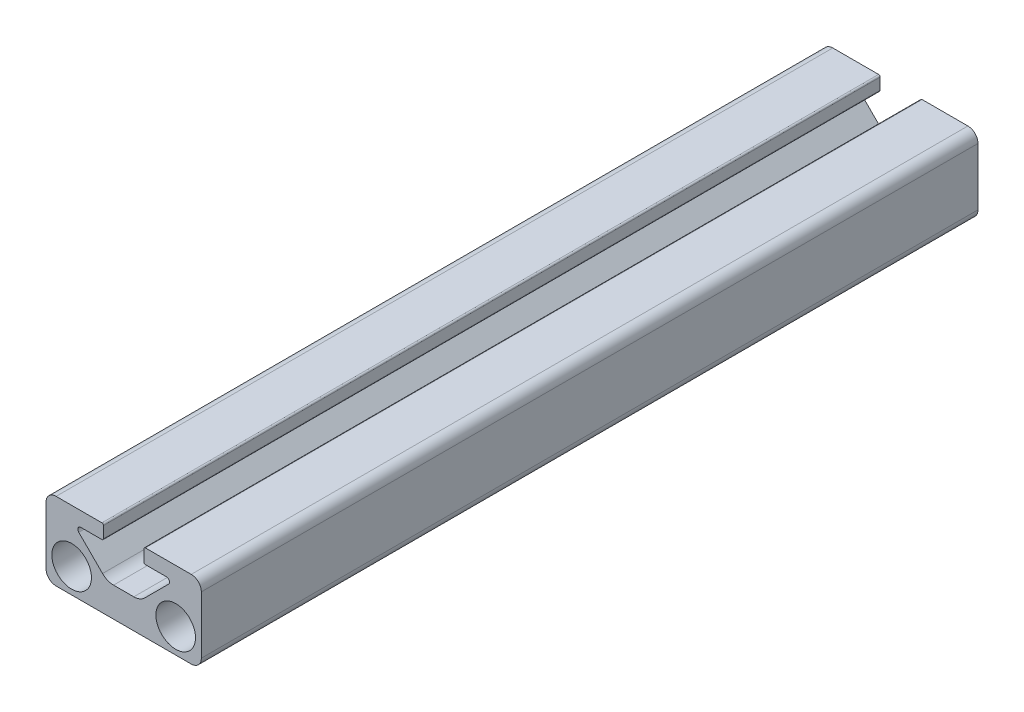
from build123d import *

# Parameters (mm, degrees)
SKETCH3_R           = 3.2385
BOSS_EXTRUDE1_DEPTH = 63.5
FILLET1_R           = 0.254


with BuildPart() as part:
    # Sketch3 → Boss-Extrude1 (new body, symmetric)
    with BuildSketch(Plane.XY):
        with BuildLine():
            Line((-11.049, 12.7), (-3.302, 12.7))
            Line((-3.302, 12.7), (-3.302, 10.328863887))
            Line((-3.302, 10.328863887), (-6.985, 10.328863887))
            ThreePointArc((-6.985, 10.328863887), (-7.454330803, 10.01526707), (-7.344210245, 9.461653642))
            Line((-7.344210245, 9.461653642), (-3.452505379, 5.569948776))
            ThreePointArc((-3.452505379, 5.569948776), (-2.628470073, 5.019345987), (-1.656454155, 4.826))
            Line((-1.656454155, 4.826), (1.656454155, 4.826))
            ThreePointArc((1.656454155, 4.826), (2.628470073, 5.019345987), (3.452505379, 5.569948776))
            Line((3.452505379, 5.569948776), (7.344210245, 9.461653642))
            ThreePointArc((7.344210245, 9.461653642), (7.454330803, 10.01526707), (6.985, 10.328863887))
            Line((6.985, 10.328863887), (3.302, 10.328863887))
            Line((3.302, 10.328863887), (3.302, 12.7))
            Line((3.302, 12.7), (11.049, 12.7))
            ThreePointArc((11.049, 12.7), (12.216433296, 12.216433296), (12.7, 11.049))
            Line((12.7, 11.049), (12.7, 1.651))
            ThreePointArc((12.7, 1.651), (12.216433296, 0.483566704), (11.049, 0))
            Line((11.049, 0), (-11.049, 0))
            ThreePointArc((-11.049, 0), (-12.216433296, 0.483566704), (-12.7, 1.651))
            Line((-12.7, 1.651), (-12.7, 11.049))
            ThreePointArc((-12.7, 11.049), (-12.216433296, 12.216433296), (-11.049, 12.7))
        make_face()
        with Locations((8.509, 4.064)):
            Circle(SKETCH3_R, mode=Mode.SUBTRACT)
        with Locations((-8.509, 4.064)):
            Circle(SKETCH3_R, mode=Mode.SUBTRACT)
    extrude(amount=BOSS_EXTRUDE1_DEPTH, both=True)

    # Fillet1
    fillet1_edges = [part.edges().sort_by_distance(p)[0] for p in [
        (-3.302, 12.7, 0),
        (-3.302, 10.328863887, 0),
        (3.302, 10.328863887, 0),
        (3.302, 12.7, 0),
    ]]
    fillet(fillet1_edges, radius=FILLET1_R)


solid = part.part
